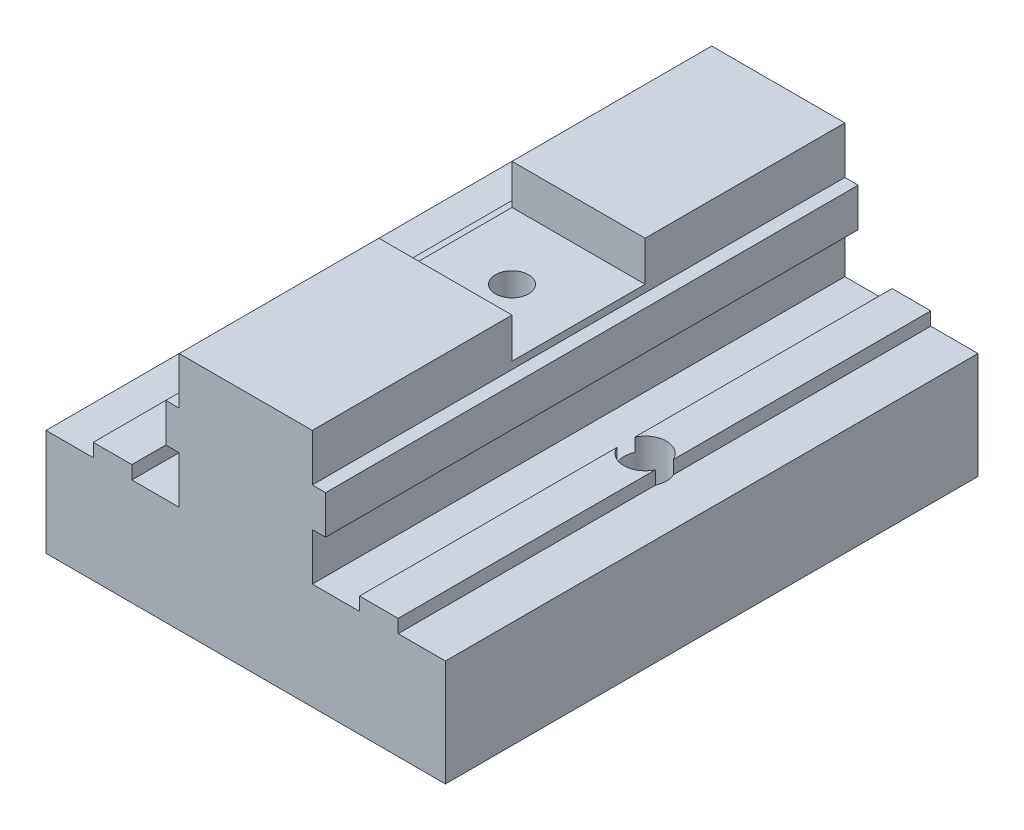
from build123d import *

# Parameters (mm, degrees)
MAIN_DEPTH         = 40
ESQUISSE2_R        = 1.6
TOPHOLE_DEPTH      = 44.657759906
ESQUISSE3_R        = 1.25
CENTRALHOLE_DEPTH  = 47.357307946
SKETCH1_R          = 4.25
CUT_EXTRUDE1_DEPTH = 5
SKETCH2_W          = 10
SKETCH2_H          = 10
CUT_EXTRUDE2_DEPTH = 3


with BuildPart() as part:
    # Esquisse1 → Main (new body)
    with BuildSketch(Plane.XY):
        Polygon((-15, 0), (-15, 8), (-11.45, 8), (-11.45, 9), (-8.55, 9), (-8.55, 8), (-5, 8), (-5, 11.55), (-6, 11.55), (-6, 14.45), (-5, 14.45), (-5, 18), (0, 18), (0, 0), align=None)
    main = extrude(amount=MAIN_DEPTH)

    # Esquisse2 → TopHole (cut, through all)
    with BuildSketch(Plane(origin=(0, 9, 0), x_dir=(1, 0, 0), z_dir=(0, 1, 0))):
        with Locations((-10, -20)):
            Circle(ESQUISSE2_R)
    tophole = extrude(amount=-TOPHOLE_DEPTH, mode=Mode.SUBTRACT)

    # Symétrie1: Main, TopHole across plane
    add(main.mirror(Plane(origin=(0, 0, 0), x_dir=(0, 0, 1), z_dir=(1, 0, 0))))
    add(tophole.mirror(Plane(origin=(0, 0, 0), x_dir=(0, 0, 1), z_dir=(1, 0, 0))), mode=Mode.SUBTRACT)

    # Esquisse3 → CentralHole (cut, through all)
    with BuildSketch(Plane(origin=(0, 18, 0), x_dir=(1, 0, 0), z_dir=(0, 1, 0))):
        with Locations((0, -20)):
            Circle(ESQUISSE3_R)
    extrude(amount=-CENTRALHOLE_DEPTH, mode=Mode.SUBTRACT)

    # Sketch1 → Cut-Extrude1 (cut)
    with BuildSketch(Plane(origin=(0, 0, 0), x_dir=(-1, 0, 0), z_dir=(0, -1, 0))):
        with Locations((10, -20)):
            Circle(SKETCH1_R)
        with Locations((-10, -20)):
            Circle(SKETCH1_R)
    extrude(amount=-CUT_EXTRUDE1_DEPTH, mode=Mode.SUBTRACT)

    # Sketch2 → Cut-Extrude2 (cut)
    with BuildSketch(Plane(origin=(0, 18, 0), x_dir=(1, 0, 0), z_dir=(0, 1, 0))):
        with Locations((0, -20)):
            Rectangle(SKETCH2_W, SKETCH2_H)
    extrude(amount=-CUT_EXTRUDE2_DEPTH, mode=Mode.SUBTRACT)


solid = part.part
